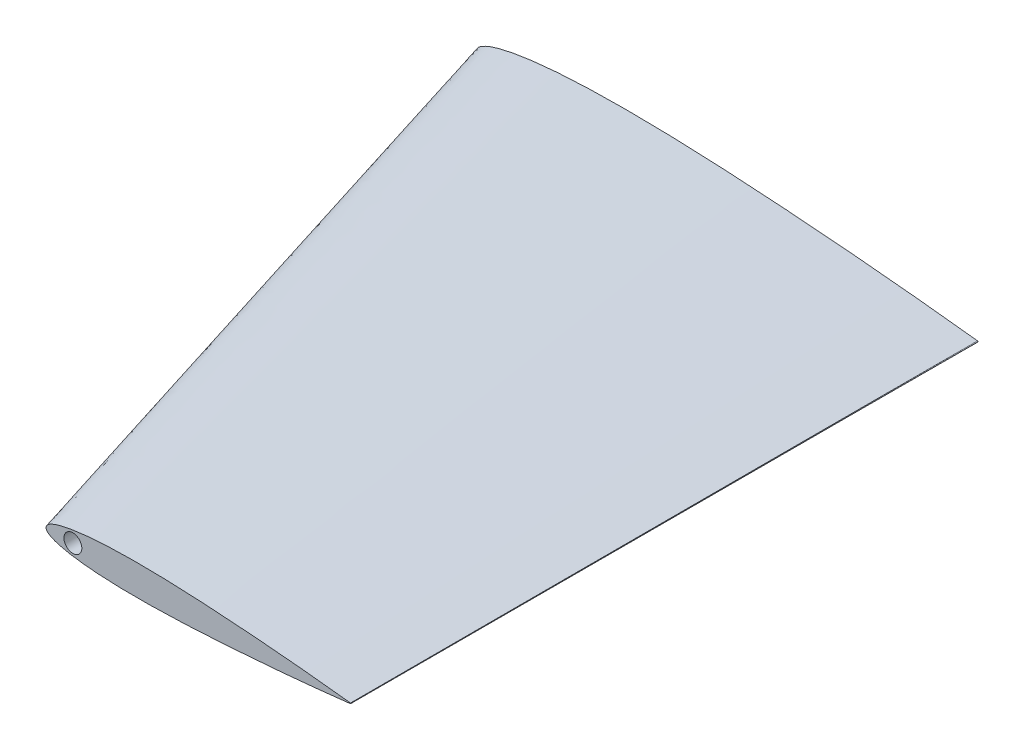
from build123d import *

# Parameters (mm, degrees)
SKETCH1_6_R         = 5
CUT_EXTRUDE_1_DEPTH = 460
SKETCH1_8_R         = 5
CUT_EXTRUDE_2_DEPTH = 175


with BuildPart() as part:
    # Sketch1 → Loft 3 section 0
    with BuildSketch(Plane.XY):
        with BuildLine():
            ThreePointArc((280, 0.294), (280.294, 0), (280, -0.294))
            add(Edge.make_bspline(
                [(0, 0), (0.045422878, -0.389894137), (0.140886477, -1.209320363), (0.873309527, -2.350467837), (1.970436326, -3.423502737), (3.475023874, -4.449210521), (5.364122015, -5.434156392), (7.638959538, -6.379158414), (10.290273079, -7.282293342), (13.310396454, -8.140699644), (16.689827167, -8.951431137), (20.418850074, -9.711257404), (24.487228418, -10.417097069), (28.884406499, -11.066012327), (33.5995416, -11.655287099), (38.621491828, -12.182438584), (43.938817855, -12.645466305), (49.539812915, -13.042530024), (55.412438609, -13.372430336), (61.544368808, -13.634329844), (67.922923642, -13.82789236), (74.535077245, -13.953106272), (81.367412665, -14.010743711), (88.406125219, -14.001651506), (95.636957993, -13.927453091), (103.045188683, -13.78997787), (110.615570489, -13.591459711), (118.332326713, -13.334519871), (126.179035503, -13.0220066), (134.138630663, -12.656995547), (142.193280464, -12.242761731), (150.324372334, -11.782773695), (158.512353088, -11.280496705), (166.736668977, -10.739604811), (174.975587766, -10.16377695), (183.206071121, -9.556637959), (191.403571246, -8.922048907), (199.54179791, -8.263872404), (207.592373823, -7.58604288), (215.524530634, -6.892797304), (225.764146977, -5.965985216), (235.720654928, -5.020019601), (245.333767678, -4.063603992), (252.078636152, -3.372940289), (258.421864008, -2.705470854), (264.280195831, -2.072973255), (269.543098561, -1.491089378), (274.046585321, -0.98236597), (277.451334935, -0.591225536), (279.328071983, -0.372360302), (280, -0.294)],
                knots=[0, 0, 0, 0, 0.004099011, 0.008614742, 0.013934855, 0.020277775, 0.027752981, 0.036410215, 0.046266433, 0.057320238, 0.069558946, 0.082962861, 0.097507218, 0.113164082, 0.12990269, 0.147690304, 0.166492185, 0.186271967, 0.206991861, 0.228612215, 0.251092165, 0.274388983, 0.298458209, 0.323253842, 0.348727971, 0.374830387, 0.40150919, 0.428710016, 0.456376154, 0.484448083, 0.512863887, 0.541558094, 0.570462313, 0.599504248, 0.628607349, 0.657690446, 0.686667237, 0.715444849, 0.743923546, 0.77199483, 0.799540253, 0.852512115, 0.877624446, 0.901571134, 0.924121062, 0.944988816, 0.963803939, 0.980044339, 0.992855276, 1, 1, 1, 1], degree=3))
            add(Edge.make_bspline(
                [(280, 0.294), (279.328071983, 0.372360302), (277.451334935, 0.591225536), (274.046585321, 0.98236597), (269.543098561, 1.491089378), (264.280195831, 2.072973255), (258.421864008, 2.705470854), (252.078636152, 3.372940289), (245.333767678, 4.063603992), (235.720654928, 5.020019601), (225.764146977, 5.965985216), (215.524530634, 6.892797304), (207.592373823, 7.58604288), (199.54179791, 8.263872404), (191.403571246, 8.922048907), (183.206071121, 9.556637959), (174.975587766, 10.16377695), (166.736668977, 10.739604811), (158.512353088, 11.280496705), (150.324372334, 11.782773695), (142.193280464, 12.242761731), (134.138630663, 12.656995547), (126.179035503, 13.0220066), (118.332326713, 13.334519871), (110.615570489, 13.591459711), (103.045188683, 13.78997787), (95.636957993, 13.927453091), (88.406125219, 14.001651506), (81.367412665, 14.010743711), (74.535077245, 13.953106272), (67.922923642, 13.82789236), (61.544368808, 13.634329844), (55.412438609, 13.372430336), (49.539812915, 13.042530024), (43.938817855, 12.645466305), (38.621491828, 12.182438584), (33.5995416, 11.655287099), (28.884406499, 11.066012327), (24.487228418, 10.417097069), (20.418850074, 9.711257404), (16.689827167, 8.951431137), (13.310396454, 8.140699644), (10.290273079, 7.282293342), (7.638959538, 6.379158414), (5.364122015, 5.434156392), (3.475023874, 4.449210521), (1.970436326, 3.423502737), (0.873309527, 2.350467837), (0.140886477, 1.209320363), (0.045422878, 0.389894137), (0, 0)],
                knots=[0, 0, 0, 0, 0.007144724, 0.019955661, 0.036196061, 0.055011184, 0.075878938, 0.098428866, 0.122375554, 0.147487885, 0.200459747, 0.22800517, 0.256076454, 0.284555151, 0.313332763, 0.342309554, 0.371392651, 0.400495752, 0.429537687, 0.458441906, 0.487136113, 0.515551917, 0.543623846, 0.571289984, 0.59849081, 0.625169613, 0.651272029, 0.676746158, 0.701541791, 0.725611017, 0.748907835, 0.771387785, 0.793008139, 0.813728033, 0.833507815, 0.852309696, 0.87009731, 0.886835918, 0.902492782, 0.917037139, 0.930441054, 0.942679762, 0.953733567, 0.963589785, 0.972247019, 0.979722225, 0.986065145, 0.991385258, 0.995900989, 1, 1, 1, 1], degree=3))
        make_face()
    # Sketch 1 → Loft 3 section 1
    with BuildSketch(Plane.XY.offset(175)):
        with BuildLine():
            Line((280, 0.23625), (280, -0.23625))
            add(Edge.make_bspline(
                [(55, 0), (55.036500527, -0.313307788), (55.113212347, -0.971775292), (55.701766584, -1.888768797), (56.583386333, -2.751028985), (57.792429899, -3.575258454), (59.310455191, -4.366732815), (61.138449629, -5.12610944), (63.268969438, -5.851842864), (65.695854293, -6.541633643), (68.411468259, -7.193114307), (71.408004524, -7.803688985), (74.677237121, -8.370881573), (78.210683794, -8.892331334), (81.999631643, -9.365855705), (86.035127361, -9.789459576), (90.307978634, -10.161535423), (94.808778235, -10.480604483), (99.527852454, -10.745702949), (104.455296364, -10.956157911), (109.580920784, -11.111699218), (114.8942585, -11.21231754), (120.384528034, -11.258633339), (126.040636336, -11.251327103), (131.851126958, -11.191703377), (137.804169477, -11.081232217), (143.887512, -10.921708697), (150.088476823, -10.715239182), (156.393867815, -10.464112446), (162.789971069, -10.170799993), (169.262457516, -9.837933534), (175.796370625, -9.468300291), (182.375998017, -9.064684852), (188.984823285, -8.63003958), (195.605383026, -8.167320764), (202.219164294, -7.679441217), (208.80644118, -7.169503586), (215.346087606, -6.640611753), (221.815300394, -6.095927315), (228.189354973, -5.538854977), (236.417618106, -4.794095263), (244.418383425, -4.033944323), (252.14320617, -3.265396065), (257.563189765, -2.710398446), (262.660426435, -2.174039079), (267.368014507, -1.66578208), (271.597132772, -1.198196822), (275.216006062, -0.789401226), (277.951965572, -0.475091948), (279.460057843, -0.2992181), (280, -0.23625)],
                knots=[0, 0, 0, 0, 0.004099011, 0.008614742, 0.013934855, 0.020277775, 0.027752981, 0.036410215, 0.046266433, 0.057320238, 0.069558946, 0.082962861, 0.097507218, 0.113164082, 0.12990269, 0.147690304, 0.166492185, 0.186271967, 0.206991861, 0.228612215, 0.251092165, 0.274388983, 0.298458209, 0.323253842, 0.348727971, 0.374830387, 0.40150919, 0.428710016, 0.456376154, 0.484448083, 0.512863887, 0.541558094, 0.570462313, 0.599504248, 0.628607349, 0.657690446, 0.686667237, 0.715444849, 0.743923546, 0.77199483, 0.799540253, 0.852512115, 0.877624446, 0.901571134, 0.924121062, 0.944988816, 0.963803939, 0.980044339, 0.992855276, 1, 1, 1, 1], degree=3))
            add(Edge.make_bspline(
                [(280, 0.23625), (279.460057843, 0.2992181), (277.951965572, 0.475091948), (275.216006062, 0.789401226), (271.597132772, 1.198196822), (267.368014507, 1.66578208), (262.660426435, 2.174039079), (257.563189765, 2.710398446), (252.14320617, 3.265396065), (244.418383425, 4.033944323), (236.417618106, 4.794095263), (228.189354973, 5.538854977), (221.815300394, 6.095927315), (215.346087606, 6.640611753), (208.80644118, 7.169503586), (202.219164294, 7.679441217), (195.605383026, 8.167320764), (188.984823285, 8.63003958), (182.375998017, 9.064684852), (175.796370625, 9.468300291), (169.262457516, 9.837933534), (162.789971069, 10.170799993), (156.393867815, 10.464112446), (150.088476823, 10.715239182), (143.887512, 10.921708697), (137.804169477, 11.081232217), (131.851126958, 11.191703377), (126.040636336, 11.251327103), (120.384528034, 11.258633339), (114.8942585, 11.21231754), (109.580920784, 11.111699218), (104.455296364, 10.956157911), (99.527852454, 10.745702949), (94.808778235, 10.480604483), (90.307978634, 10.161535423), (86.035127361, 9.789459576), (81.999631643, 9.365855705), (78.210683794, 8.892331334), (74.677237121, 8.370881573), (71.408004524, 7.803688985), (68.411468259, 7.193114307), (65.695854293, 6.541633643), (63.268969438, 5.851842864), (61.138449629, 5.12610944), (59.310455191, 4.366732815), (57.792429899, 3.575258454), (56.583386333, 2.751028985), (55.701766584, 1.888768797), (55.113212347, 0.971775292), (55.036500527, 0.313307788), (55, 0)],
                knots=[0, 0, 0, 0, 0.007144724, 0.019955661, 0.036196061, 0.055011184, 0.075878938, 0.098428866, 0.122375554, 0.147487885, 0.200459747, 0.22800517, 0.256076454, 0.284555151, 0.313332763, 0.342309554, 0.371392651, 0.400495752, 0.429537687, 0.458441906, 0.487136113, 0.515551917, 0.543623846, 0.571289984, 0.59849081, 0.625169613, 0.651272029, 0.676746158, 0.701541791, 0.725611017, 0.748907835, 0.771387785, 0.793008139, 0.813728033, 0.833507815, 0.852309696, 0.87009731, 0.886835918, 0.902492782, 0.917037139, 0.930441054, 0.942679762, 0.953733567, 0.963589785, 0.972247019, 0.979722225, 0.986065145, 0.991385258, 0.995900989, 1, 1, 1, 1], degree=3))
        make_face()
    # Sketch 2 → Loft 3 section 2
    with BuildSketch(Plane.XY.offset(350)):
        with BuildLine():
            Line((280, 0.1785), (280, -0.1785))
            add(Edge.make_bspline(
                [(110, 0), (110.027578176, -0.23672144), (110.085538218, -0.73423022), (110.530223642, -1.427069758), (111.196336341, -2.078555233), (112.109835923, -2.701306388), (113.256788366, -3.299309238), (114.63793972, -3.873060466), (116.247665798, -4.421392386), (118.081312133, -4.942567641), (120.133109351, -5.434797476), (122.397158974, -5.896120566), (124.867245825, -6.324666077), (127.536961089, -6.718650341), (130.399721686, -7.07642431), (133.448762895, -7.396480569), (136.677139412, -7.677604542), (140.077743555, -7.918678943), (143.643266298, -8.118975561), (147.366223919, -8.277985977), (151.238917925, -8.395506076), (155.253439756, -8.471528808), (159.401643404, -8.506522967), (163.675147454, -8.5010027), (168.065295924, -8.455953662), (172.563150272, -8.372486564), (177.159453511, -8.251957682), (181.844626933, -8.095958493), (186.608700127, -7.906218293), (191.441311474, -7.684604439), (196.331634567, -7.433105337), (201.268368917, -7.153826886), (206.239642946, -6.848873), (211.232977593, -6.52047435), (216.235178286, -6.170864577), (221.232257467, -5.802244475), (226.209311114, -5.416958265), (231.150377303, -5.017351103), (236.038226964, -4.605811749), (240.854179313, -4.184912649), (247.071089236, -3.62220531), (253.116111921, -3.047869044), (258.952644662, -2.467188138), (263.047743378, -2.047856604), (266.898988862, -1.642607304), (270.455833183, -1.258590905), (273.651166984, -0.905304265), (276.385426802, -0.596436482), (278.45259621, -0.358958361), (279.592043704, -0.226075898), (280, -0.1785)],
                knots=[0, 0, 0, 0, 0.004099011, 0.008614742, 0.013934855, 0.020277775, 0.027752981, 0.036410215, 0.046266433, 0.057320238, 0.069558946, 0.082962861, 0.097507218, 0.113164082, 0.12990269, 0.147690304, 0.166492185, 0.186271967, 0.206991861, 0.228612215, 0.251092165, 0.274388983, 0.298458209, 0.323253842, 0.348727971, 0.374830387, 0.40150919, 0.428710016, 0.456376154, 0.484448083, 0.512863887, 0.541558094, 0.570462313, 0.599504248, 0.628607349, 0.657690446, 0.686667237, 0.715444849, 0.743923546, 0.77199483, 0.799540253, 0.852512115, 0.877624446, 0.901571134, 0.924121062, 0.944988816, 0.963803939, 0.980044339, 0.992855276, 1, 1, 1, 1], degree=3))
            add(Edge.make_bspline(
                [(280, 0.1785), (279.592043704, 0.226075898), (278.45259621, 0.358958361), (276.385426802, 0.596436482), (273.651166984, 0.905304265), (270.455833183, 1.258590905), (266.898988862, 1.642607304), (263.047743378, 2.047856604), (258.952644662, 2.467188138), (253.116111921, 3.047869044), (247.071089236, 3.62220531), (240.854179313, 4.184912649), (236.038226964, 4.605811749), (231.150377303, 5.017351103), (226.209311114, 5.416958265), (221.232257467, 5.802244475), (216.235178286, 6.170864577), (211.232977593, 6.52047435), (206.239642946, 6.848873), (201.268368917, 7.153826886), (196.331634567, 7.433105337), (191.441311474, 7.684604439), (186.608700127, 7.906218293), (181.844626933, 8.095958493), (177.159453511, 8.251957682), (172.563150272, 8.372486564), (168.065295924, 8.455953662), (163.675147454, 8.5010027), (159.401643404, 8.506522967), (155.253439756, 8.471528808), (151.238917925, 8.395506076), (147.366223919, 8.277985977), (143.643266298, 8.118975561), (140.077743555, 7.918678943), (136.677139412, 7.677604542), (133.448762895, 7.396480569), (130.399721686, 7.07642431), (127.536961089, 6.718650341), (124.867245825, 6.324666077), (122.397158974, 5.896120566), (120.133109351, 5.434797476), (118.081312133, 4.942567641), (116.247665798, 4.421392386), (114.63793972, 3.873060466), (113.256788366, 3.299309238), (112.109835923, 2.701306388), (111.196336341, 2.078555233), (110.530223642, 1.427069758), (110.085538218, 0.73423022), (110.027578176, 0.23672144), (110, 0)],
                knots=[0, 0, 0, 0, 0.007144724, 0.019955661, 0.036196061, 0.055011184, 0.075878938, 0.098428866, 0.122375554, 0.147487885, 0.200459747, 0.22800517, 0.256076454, 0.284555151, 0.313332763, 0.342309554, 0.371392651, 0.400495752, 0.429537687, 0.458441906, 0.487136113, 0.515551917, 0.543623846, 0.571289984, 0.59849081, 0.625169613, 0.651272029, 0.676746158, 0.701541791, 0.725611017, 0.748907835, 0.771387785, 0.793008139, 0.813728033, 0.833507815, 0.852309696, 0.87009731, 0.886835918, 0.902492782, 0.917037139, 0.930441054, 0.942679762, 0.953733567, 0.963589785, 0.972247019, 0.979722225, 0.986065145, 0.991385258, 0.995900989, 1, 1, 1, 1], degree=3))
        make_face()
    loft()

    # Sketch1_6 → Cut-Extrude 1 (cut)
    with BuildSketch(Plane.XY):
        with Locations((125, 0)):
            Circle(SKETCH1_6_R)
    extrude(amount=CUT_EXTRUDE_1_DEPTH, mode=Mode.SUBTRACT)

    # Sketch1_8 → Cut-Extrude 2 (cut)
    with BuildSketch(Plane.XY):
        with Locations((82, 0)):
            Circle(SKETCH1_8_R)
    extrude(amount=CUT_EXTRUDE_2_DEPTH, mode=Mode.SUBTRACT)


solid = part.part
